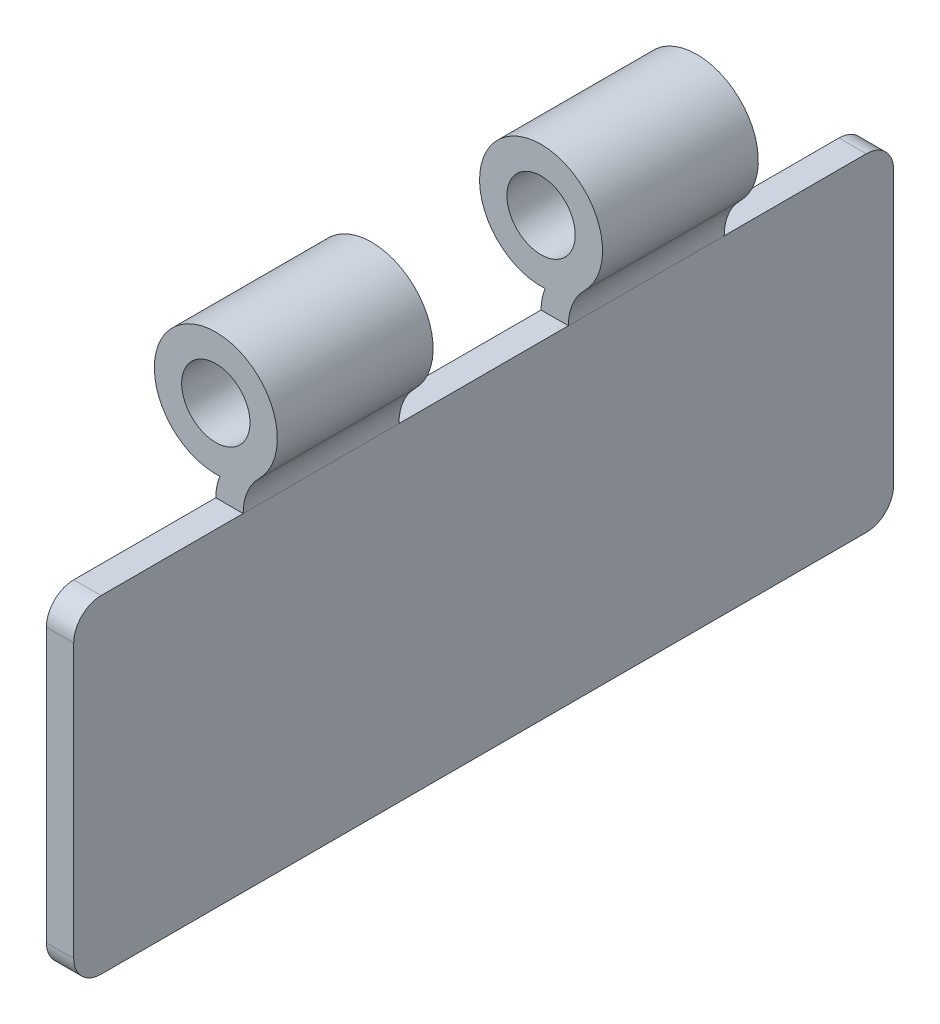
from build123d import *

# Parameters (mm, degrees)
SKETCH1_R           = 3.175
BOSS_EXTRUDE1_DEPTH = 38.1
SKETCH1_3_R         = 3.175
CUT_EXTRUDE1_DEPTH  = 7.874
SKETCH2_R           = 3.175
CUT_EXTRUDE2_DEPTH  = 15.748
FILLET1_R           = 2.54


with BuildPart() as part:
    # Sketch1 → Boss-Extrude1 (new, symmetric)
    with BuildSketch(Plane.XY):
        with BuildLine():
            Line((0, 0), (2.54, 0))
            Line((2.54, 0), (2.54, 30.48))
            ThreePointArc((2.54, 30.48), (2.925884615, 32.409423077), (4.024171598, 34.042011834))
            ThreePointArc((4.024171598, 34.042011834), (-2.351034724, 43.309017251), (0.381023909, 32.39771574))
            ThreePointArc((0.381023909, 32.39771574), (0.096177955, 31.457600747), (0, 30.48))
            Line((0, 30.48), (0, 0))
        make_face()
        with Locations((0, 38.1)):
            Circle(SKETCH1_R, mode=Mode.SUBTRACT)
    extrude(amount=BOSS_EXTRUDE1_DEPTH, both=True)

    # Sketch1_3 → Cut-Extrude1 (cut, symmetric)
    with BuildSketch(Plane.XY):
        with BuildLine():
            Line((0, 30.48), (2.54, 30.48))
            ThreePointArc((2.54, 30.48), (2.925884615, 32.409423077), (4.024171598, 34.042011834))
            ThreePointArc((4.024171598, 34.042011834), (-2.351034724, 43.309017251), (0.381023909, 32.39771574))
            ThreePointArc((0.381023909, 32.39771574), (0.096177955, 31.457600747), (0, 30.48))
        make_face()
        with Locations((0, 38.1)):
            Circle(SKETCH1_3_R, mode=Mode.SUBTRACT)
    extrude(amount=CUT_EXTRUDE1_DEPTH, both=True, mode=Mode.SUBTRACT)

    # Sketch2 → Cut-Extrude2 (cut)
    with BuildSketch(Plane.XY.offset(38.1)):
        with BuildLine():
            Line((2.54, 30.48), (0, 30.48))
            ThreePointArc((0, 30.48), (0.096177955, 31.457600747), (0.381023909, 32.39771574))
            ThreePointArc((0.381023909, 32.39771574), (-2.351034724, 43.309017251), (4.024171598, 34.042011834))
            ThreePointArc((4.024171598, 34.042011834), (2.925884615, 32.409423077), (2.54, 30.48))
        make_face()
        with Locations((0, 38.1)):
            Circle(SKETCH2_R, mode=Mode.SUBTRACT)
    cut_extrude2 = extrude(amount=-CUT_EXTRUDE2_DEPTH, mode=Mode.SUBTRACT)

    # Mirror1: Cut-Extrude2 across plane
    add(cut_extrude2.mirror(Plane.XY), mode=Mode.SUBTRACT)

    # Fillet1
    fillet1_edges = [part.edges().sort_by_distance(p)[0] for p in [
        (1.27, 0, 38.1),
        (1.27, 30.48, 38.1),
        (1.27, 0, -38.1),
        (1.27, 30.48, -38.1),
    ]]
    fillet(fillet1_edges, radius=FILLET1_R)


solid = part.part
